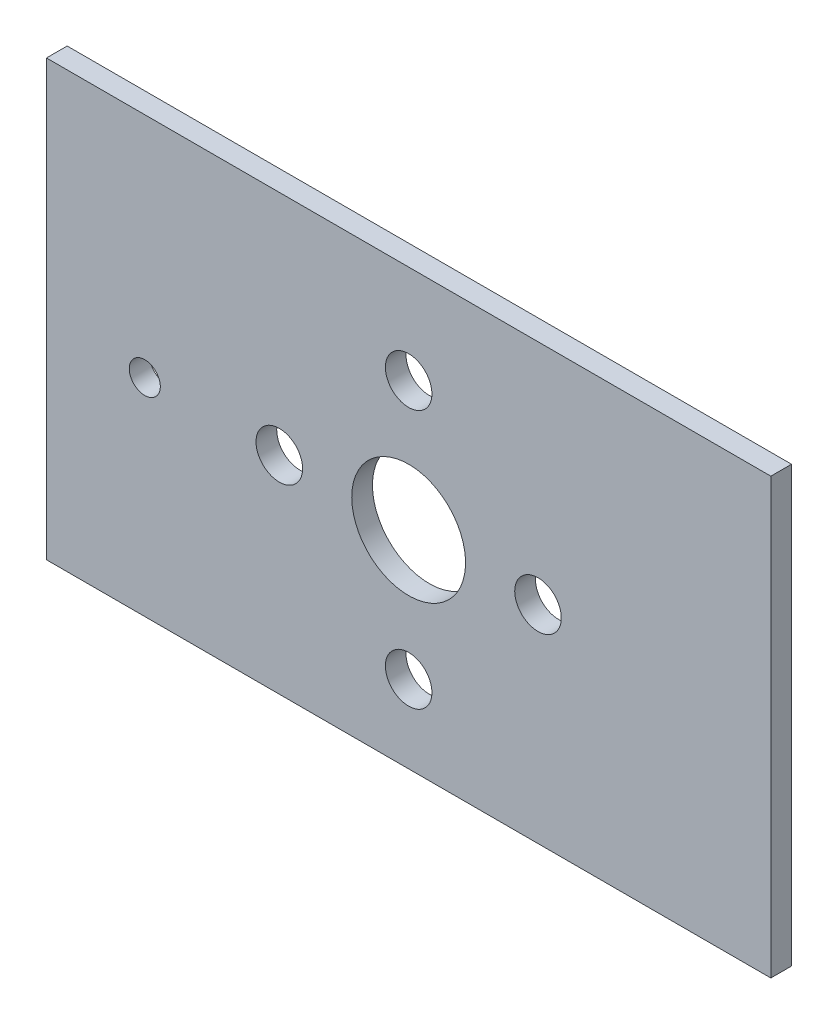
from build123d import *

# Parameters (mm, degrees)
ESQUISSE1_W             = 70
ESQUISSE1_H             = 42
BOSS_EXTRU_1_DEPTH      = 2
D_GAGEMENT_M41_D        = 4.5
ESQUISSE4_R             = 5.5
ENL_V_MAT_EXTRU_1_DEPTH = 3
ESQUISSE2_R             = 1.5
ENL_V_MAT_EXTRU_2_DEPTH = 3


with BuildPart() as part:
    # Esquisse1 → Boss.-Extru.1 (new body)
    with BuildSketch(Plane.XY):
        with Locations((35, 21)):
            Rectangle(ESQUISSE1_W, ESQUISSE1_H)
    extrude(amount=BOSS_EXTRU_1_DEPTH)

    # Dégagement M41 (through all)
    with Locations(Plane(origin=(35, 32.5, 0), x_dir=(-1, 0, 0), z_dir=(0, 0, -1))):
        with Locations((0, 0), (-12.5, -12.5), (0, -25), (12.5, -12.5)):
            Hole(D_GAGEMENT_M41_D / 2)

    # Esquisse4 → Enlèv. mat.-Extru.1 (cut, through all)
    with BuildSketch(Plane(origin=(0, 0, 0), x_dir=(-1, 0, 0), z_dir=(0, 0, -1))):
        with Locations((-35, 20)):
            Circle(ESQUISSE4_R)
    extrude(amount=-ENL_V_MAT_EXTRU_1_DEPTH, mode=Mode.SUBTRACT)

    # Esquisse2 → Enlèv. mat.-Extru.2 (cut, through all)
    with BuildSketch(Plane(origin=(0, 0, 0), x_dir=(-1, 0, 0), z_dir=(0, 0, -1))):
        with Locations((-9.5, 20)):
            Circle(ESQUISSE2_R)
    extrude(amount=-ENL_V_MAT_EXTRU_2_DEPTH, mode=Mode.SUBTRACT)


solid = part.part
